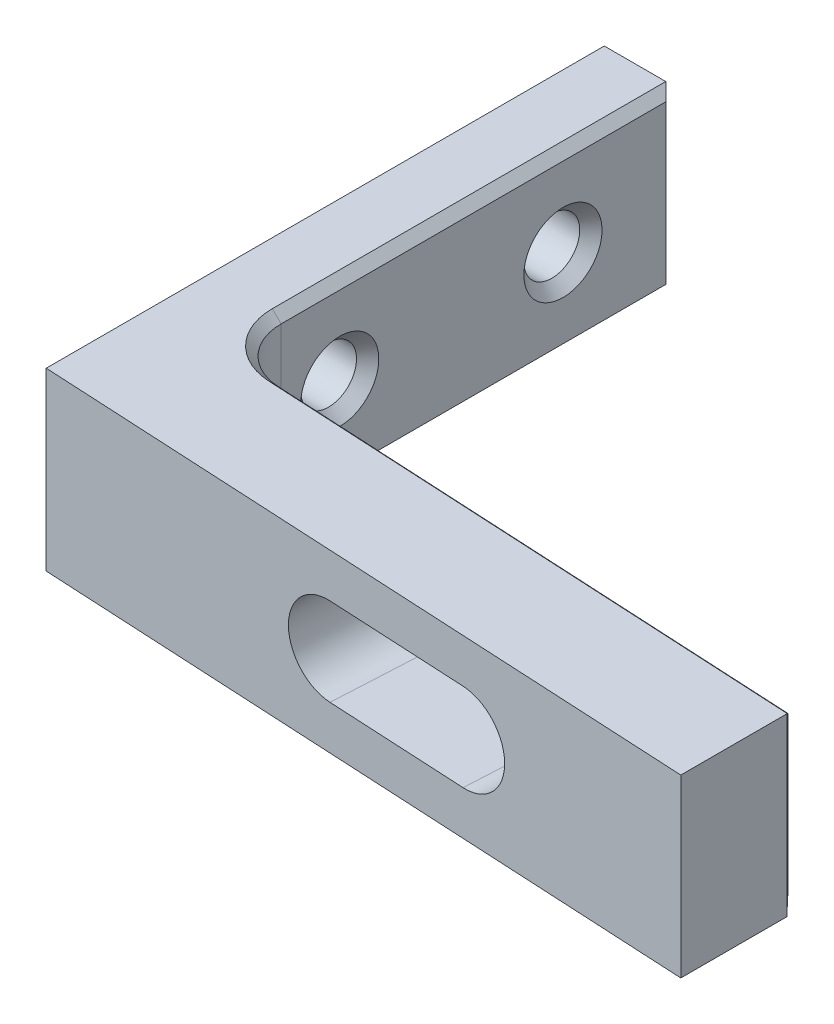
from build123d import *
from OCP.BRepFilletAPI import BRepFilletAPI_MakeChamfer

# Parameters (mm, degrees)
SKETCH1_W                             = 38.1
SKETCH1_H                             = 31.75
BOSS_EXTRUDE1_DEPTH                   = 10
CUT_EXTRUDE1_REACH                    = 28.738
SKETCH2_W                             = 34.1
SKETCH2_H                             = 25.4
F_1_8_0_125_DIAMETER_HOLE1_AT_2_COUNT = 2
F_1_8_0_125_DIAMETER_HOLE1_AT_2_PITCH = 12.7
DRAFT1_ANGLE                          = 3
CUT_EXTRUDE2_DEPTH                    = 28.969652512
CUT_EXTRUDE3_DEPTH                    = 35.177500808
FILLET2_R                             = 3.175
CHAMFER1_SIZE                         = 0.5
CHAMFER2_SIZE                         = 0.5
CHAMFER2_SIZE2                        = 0.528377251


with BuildPart() as part:
    # Sketch1 → Boss-Extrude1 (new body)
    with BuildSketch(Plane(origin=(0, 0, 0), x_dir=(1, 0, 0), z_dir=(0, 1, 0))):
        Rectangle(SKETCH1_W, SKETCH1_H)
    extrude(amount=BOSS_EXTRUDE1_DEPTH)

    # Sketch2 → Cut-Extrude1 (cut, up to next)
    with BuildSketch(Plane(origin=(0, 10, 0), x_dir=(1, 0, 0), z_dir=(0, 1, 0)), mode=Mode.PRIVATE) as cut_extrude1_sk1:
        with Locations((2, 3.175)):
            Rectangle(SKETCH2_W, SKETCH2_H)
    cut_extrude1_tool1 = extrude(cut_extrude1_sk1.sketch, amount=-CUT_EXTRUDE1_REACH, mode=Mode.PRIVATE) & part.part
    add(cut_extrude1_tool1.solids().sort_by_distance((2, 10, -3.175))[0], mode=Mode.SUBTRACT)

    # Sketch3 → 1/8 (0.125) Diameter Hole1 (revolve, cut)
    with BuildSketch(Plane(origin=(-19.05, 5, -9.525), x_dir=(0, 0, 1), z_dir=(0, 1, 0))):
        Polygon((0, 0), (0, 4), (2.2225, 4), (1.5875, 3.365), (1.5875, 0.635), (2.2225, 0), align=None)
    f_1_8_0_125_diameter_hole1 = revolve(axis=Axis((-25.4, 5, -9.525), (1, 0, 0)), mode=Mode.SUBTRACT)

    # 1/8 (0.125) Diameter Hole1 at 2: 1/8 (0.125) Diameter Hole1 ×2
    with Locations(*[(0, 0, i * F_1_8_0_125_DIAMETER_HOLE1_AT_2_PITCH) for i in range(1, F_1_8_0_125_DIAMETER_HOLE1_AT_2_COUNT)]):
        add(f_1_8_0_125_diameter_hole1, mode=Mode.SUBTRACT)

    # Draft1
    draft1_faces = [part.faces().sort_by_distance(p)[0] for p in [
        (0, 5, 15.875),
    ]]
    draft(draft1_faces, Plane(origin=(-19.05, 10, 15.875), x_dir=(0, 0, -1), z_dir=(-1, 0, 0)), DRAFT1_ANGLE)

    # Sketch7 → Cut-Extrude2 (cut, through all)
    with BuildSketch(Plane(origin=(0, 10, 0), x_dir=(1, 0, 0), z_dir=(0, 1, 0))):
        Polygon((-15.05, -9.525), (19.05, -9.525), (19.05, -11.312105274), align=None)
    extrude(amount=-CUT_EXTRUDE2_DEPTH, mode=Mode.SUBTRACT)

    # Sketch8 → Cut-Extrude3 (cut, through all)
    with BuildSketch(Plane(origin=(-0.539039544, 0, 10.285487213), x_dir=(-0.9986295347545739, 0, -0.05233595624294398), z_dir=(0.05233595624294399, 0, -0.998629534754574))):
        with BuildLine():
            Line((-6.869125485, 7.5), (1.130874515, 7.5))
            ThreePointArc((1.130874515, 7.5), (3.630874515, 5), (1.130874515, 2.5))
            Line((1.130874515, 2.5), (-6.869125485, 2.5))
            ThreePointArc((-6.869125485, 2.5), (-9.369125485, 5), (-6.869125485, 7.5))
        make_face()
    extrude(amount=-CUT_EXTRUDE3_DEPTH, mode=Mode.SUBTRACT)

    # Fillet2
    fillet2_edges = [part.edges().sort_by_distance(p)[0] for p in [
        (-15.05, 5, 9.525),
    ]]
    fillet(fillet2_edges, radius=FILLET2_R)

    # Chamfer1
    chamfer1_edges = [part.edges().sort_by_distance(p)[0] for p in [
        (8.817245881, 5, 10.775829354),
        (2.326153905, 2.5, 10.435645639),
        (-4.164938071, 5, 10.095461923),
        (2.326153905, 7.5, 10.435645639),
    ]]
    chamfer(chamfer1_edges, length=CHAMFER1_SIZE)

    # Chamfer2: one chamfer whose edges measure the first distance from different faces: ONE call of the kernel's chamfer builder (chamfer() names one face for all edges)
    chamfer2_edges_1 = [part.edges().sort_by_distance(p)[0] for p in [
        (-15.05, 0, -4.68148125),
        (-15.05, 5, -15.875),
        (-15.05, 10, -4.68148125),
        (3.504416669, 10, 10.497395774),
        (3.504416669, 0, 10.497395774),
        (-14.178063628, 10, 8.697563279),
        (-14.178063628, 0, 8.697563279),
    ]]
    chamfer2_edges_2 = [part.edges().sort_by_distance(p)[0] for p in [
        (19.05, 5, 11.312105274),
    ]]
    chamfer2_side_2 = [part.faces().sort_by_distance(p)[0] for p in [
        (9.643116423, 5, 10.819111395),
    ]]
    chamfer2 = BRepFilletAPI_MakeChamfer(part.part.solid().wrapped)
    for e in chamfer2_edges_1:
        chamfer2.Add(CHAMFER2_SIZE, e.wrapped)
    for e in chamfer2_edges_2:
        chamfer2.Add(CHAMFER2_SIZE, CHAMFER2_SIZE2, e.wrapped, chamfer2_side_2[0].wrapped)  # the first distance lies on this face
    add(Compound.cast(chamfer2.Shape()), mode=Mode.REPLACE)


solid = part.part
